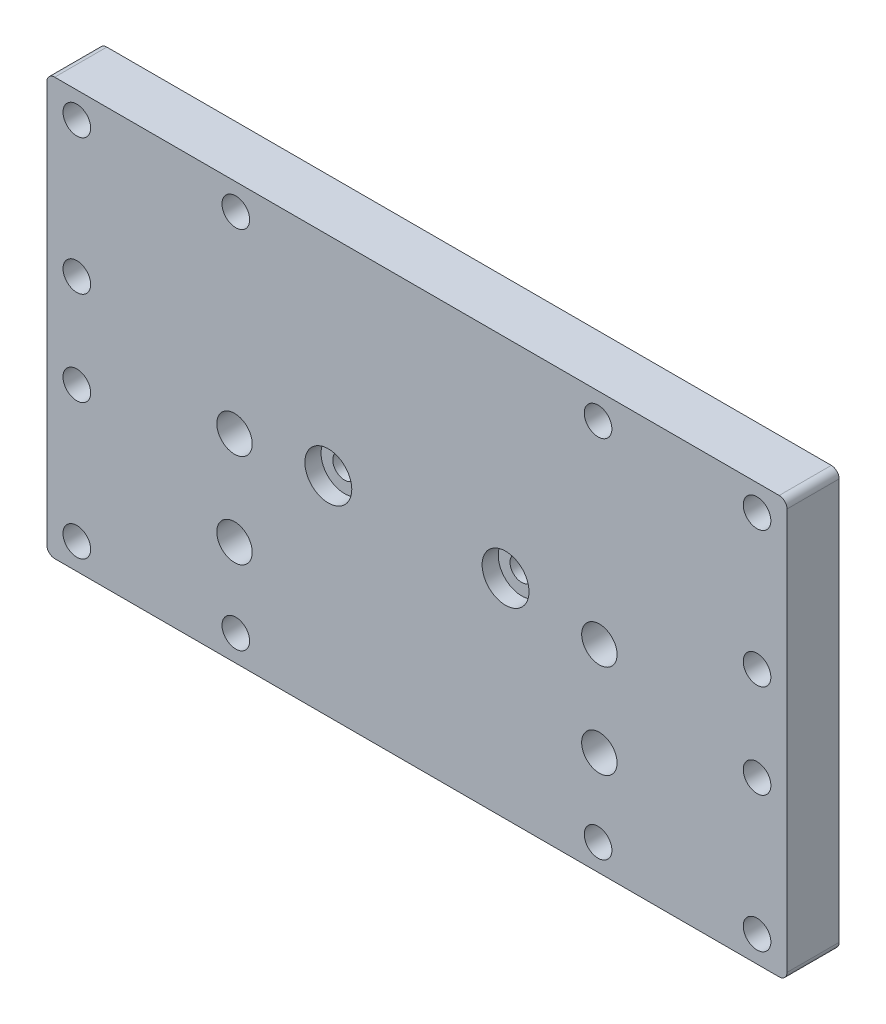
from build123d import *

# Parameters (mm, degrees)
SKETCH1_W                                        = 142
SKETCH1_H                                        = 80
BOSS_EXTRUDE1_DEPTH                              = 5
M5_CLEARANCE_HOLE1_D                             = 5.3
MIRROR2_COPY_1_D                                 = 5.3
CBORE_FOR_M4_PAN_HEAD_MACHINE_SCREW1_D           = 4.5
CBORE_FOR_M4_PAN_HEAD_MACHINE_SCREW1_CBORE_D     = 9
CBORE_FOR_M4_PAN_HEAD_MACHINE_SCREW1_CBORE_DEPTH = 3.1
M8X1_25_TAPPED_HOLE1_D                           = 6.8
FILLET1_R                                        = 1.5


with BuildPart() as part:
    # Sketch1 → Boss-Extrude1 (new body, symmetric)
    with BuildSketch(Plane.XY):
        Rectangle(SKETCH1_W, SKETCH1_H)
    extrude(amount=BOSS_EXTRUDE1_DEPTH, both=True)

    # M5 Clearance Hole1 (through all)
    with Locations(Plane.XY.offset(5)):
        with Locations((-65.25, 35), (-34.75, 35), (-65.25, 9)):
            m5_clearance_hole1 = Hole(M5_CLEARANCE_HOLE1_D / 2)

    # Mirror1: M5 Clearance Hole1 across plane
    add(m5_clearance_hole1.mirror(Plane(origin=(0, 0, 0), x_dir=(0, 0, 1), z_dir=(1, 0, 0))), mode=Mode.SUBTRACT)

    # Mirror2: M5 Clearance Hole1 across plane
    add(m5_clearance_hole1.mirror(Plane.ZX), mode=Mode.SUBTRACT)

    # Mirror2 copy 1 (through all)
    with Locations(Plane(origin=(0, 0, 5), x_dir=(-1, 0, 0), z_dir=(0, 0, 1))):
        with Locations((-65.25, 35), (-34.75, 35), (-65.25, 9)):
            Hole(MIRROR2_COPY_1_D / 2)

    # CBORE for M4 Pan Head Machine Screw1 (through all)
    with Locations(Plane(origin=(-50.308370618, 7.533390419, 5), x_dir=(1, 0, 0), z_dir=(0, 0, 1))):
        with Locations((33.308370618, -7.533390419), (67.308370618, -7.533390419)):
            CounterBoreHole(CBORE_FOR_M4_PAN_HEAD_MACHINE_SCREW1_D / 2, CBORE_FOR_M4_PAN_HEAD_MACHINE_SCREW1_CBORE_D / 2, CBORE_FOR_M4_PAN_HEAD_MACHINE_SCREW1_CBORE_DEPTH)

    # M8x1.25 Tapped Hole1 (through all)
    with Locations(Plane.XY.offset(5)):
        with Locations((-35, -2), (35, -2), (35, -20), (-35, -20)):
            Hole(M8X1_25_TAPPED_HOLE1_D / 2)

    # Fillet1
    fillet1_edges = [part.edges().sort_by_distance(p)[0] for p in [
        (71, -40, 0),
        (-71, -40, 0),
        (-71, 40, 0),
        (71, 40, 0),
    ]]
    fillet(fillet1_edges, radius=FILLET1_R)


solid = part.part
